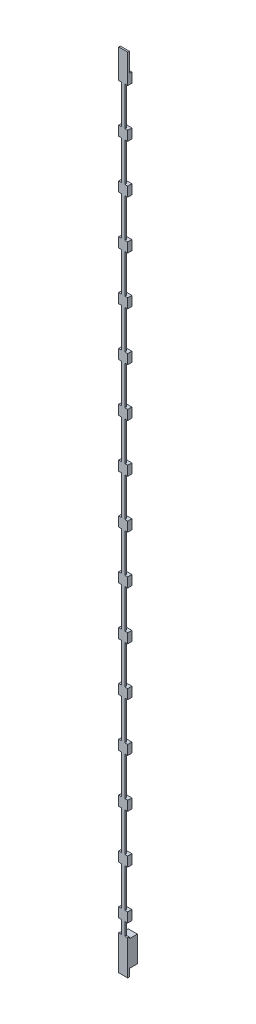
from build123d import *

# Parameters (mm, degrees)
SKETCH2_W           = 5.58
SKETCH2_H           = 21.51
BOSS_EXTRUDE1_DEPTH = 0.5
BOSS_EXTRUDE2_DEPTH = 0.5
SKETCH4_W           = 5.58
SKETCH4_H           = 6
BOSS_EXTRUDE3_DEPTH = 2.6
LPATTERN1_COUNT     = 16
LPATTERN1_PITCH     = 30
SKETCH5_W           = 5.58
SKETCH5_H           = 1
BOSS_EXTRUDE4_DEPTH = 12
SKETCH9_W           = 5.58
SKETCH9_H           = 16
BOSS_EXTRUDE6_DEPTH = 5


with BuildPart() as part:
    # Sketch2 → Boss-Extrude1 (new body, symmetric)
    with BuildSketch(Plane.XY):
        with Locations((0, 10.755)):
            Rectangle(SKETCH2_W, SKETCH2_H)
    extrude(amount=BOSS_EXTRUDE1_DEPTH, both=True)

    # Sketch3 → Boss-Extrude2 (add, symmetric)
    with BuildSketch(Plane.XY):
        Polygon((-2.79, 35.51), (2.79, 35.51), (2.79, 29.51), (1, 29.51), (1, 4.51), (-1, 4.51), (-1, 29.51), (-2.79, 29.51), align=None)
    boss_extrude2 = extrude(amount=BOSS_EXTRUDE2_DEPTH, both=True)

    # Sketch4 → Boss-Extrude3 (add)
    with BuildSketch(Plane.XY.offset(0.5)):
        with Locations((0, 32.51)):
            Rectangle(SKETCH4_W, SKETCH4_H)
    boss_extrude3 = extrude(amount=-BOSS_EXTRUDE3_DEPTH)

    # LPattern1: Boss-Extrude2, Boss-Extrude3 ×16
    with Locations(*[(0, i * LPATTERN1_PITCH, 0) for i in range(1, LPATTERN1_COUNT)]):
        add(boss_extrude2)
        add(boss_extrude3)

    # Sketch5 → Boss-Extrude4 (add)
    with BuildSketch(Plane(origin=(0, 485.51, 0), x_dir=(1, 0, 0), z_dir=(0, 1, 0))):
        Rectangle(SKETCH5_W, SKETCH5_H)
    extrude(amount=BOSS_EXTRUDE4_DEPTH)

    # Sketch9 → Boss-Extrude6 (add)
    with BuildSketch(Plane.XY.offset(-0.5)):
        with Locations((0, 12.61)):
            Rectangle(SKETCH9_W, SKETCH9_H)
    extrude(amount=-BOSS_EXTRUDE6_DEPTH)


solid = part.part
